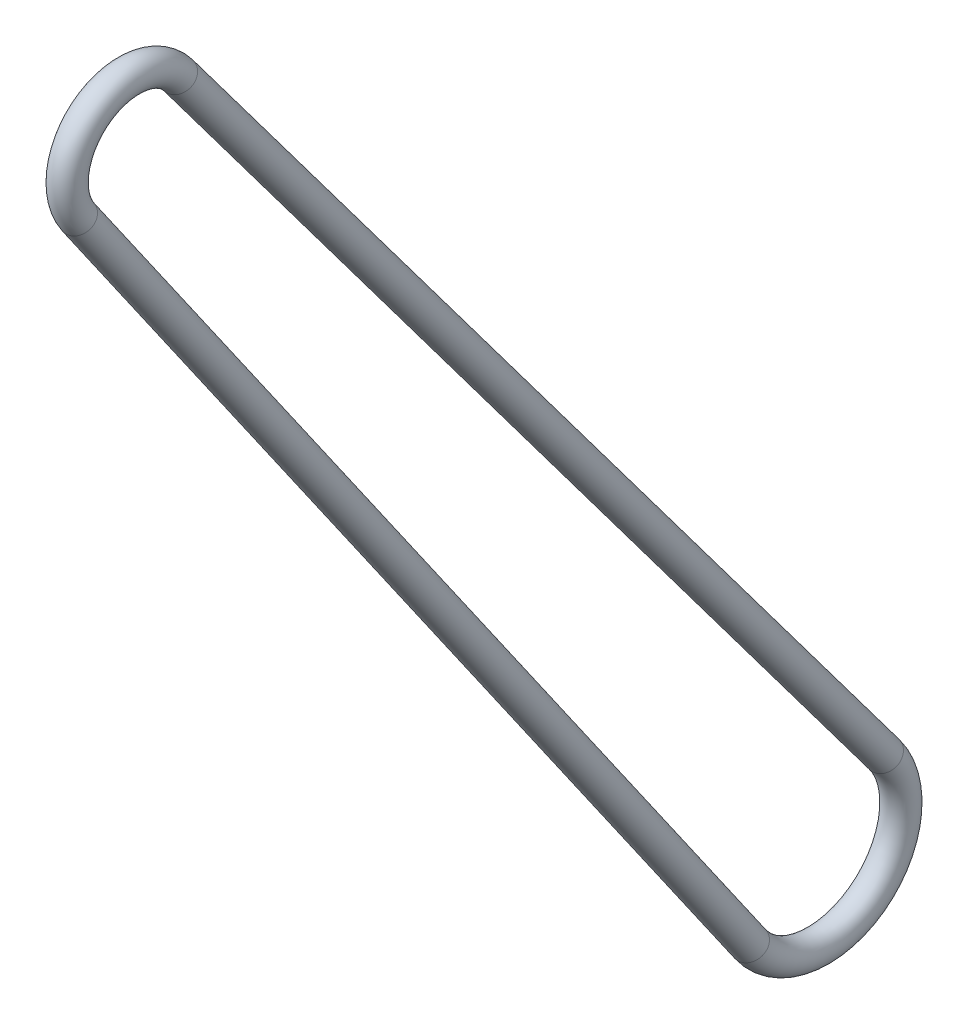
from build123d import *

# Parameters (mm, degrees)
SKETCH2_R = 1.984375


with BuildPart() as part:
    # Sweep1: sweep along a path in Sketch1
    with BuildLine(Plane(origin=(0, 0, 0), x_dir=(0, 0, -1), z_dir=(1, 0, 0))) as sweep1_path:
        Line((100.349736587, -120.069650872), (6.57549425, 4.932799243))
        ThreePointArc((6.57549425, 4.932799243), (-4.815061709, 6.662192863), (-6.746783583, -4.695800707))
        Line((-6.746783583, -4.695800707), (82.522033534, -132.954521078))
        ThreePointArc((82.522033534, -132.954521078), (97.993948111, -135.585922095), (100.349736587, -120.069650872))
    # Sketch2 → Sweep1 (sweep)
    with BuildSketch(Plane(origin=(0, 4.932799243, -6.57549425), x_dir=(1, 0, 0), z_dir=(0, 0.7999311746157586, 0.6000917562155417))):
        Circle(SKETCH2_R)
    sweep(path=sweep1_path.line)


solid = part.part
